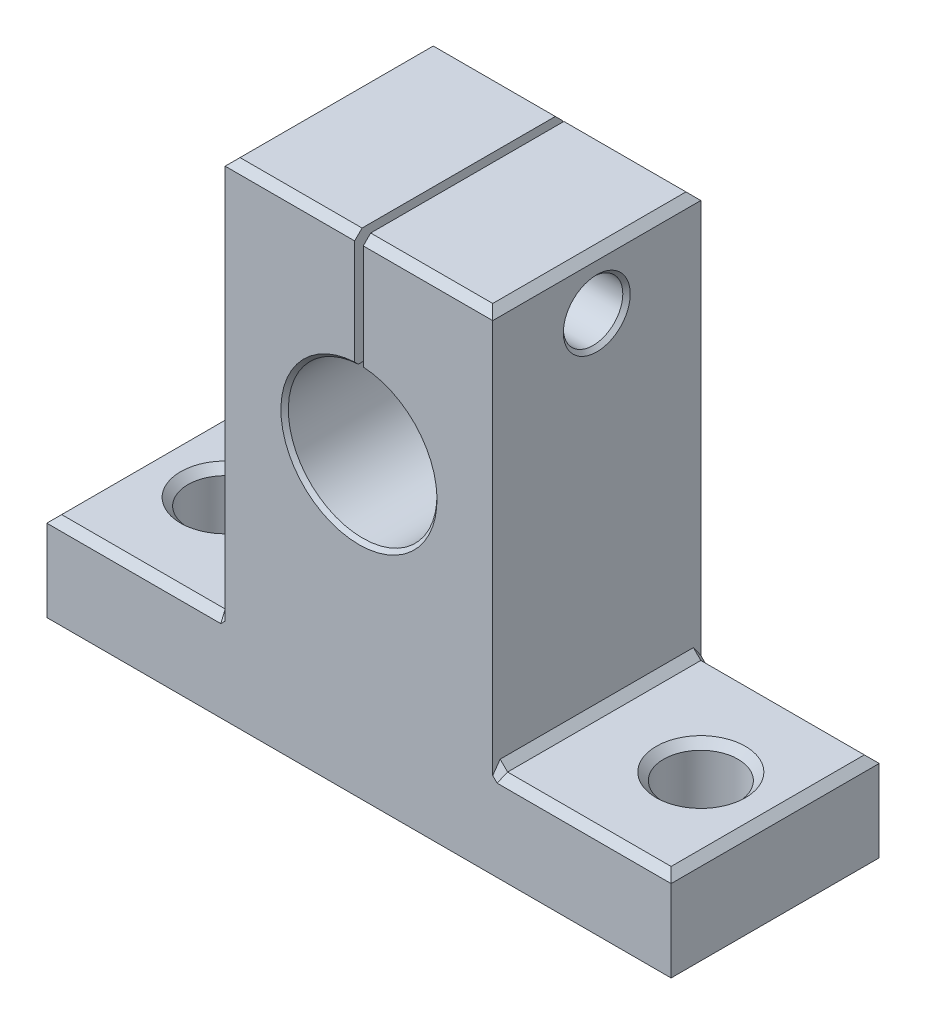
from build123d import *

# Parameters (mm, degrees)
BOSS_EXTRUDE1_DEPTH = 14
CHAMFER1_SIZE       = 0.5
CHAMFER2_SIZE       = 0.5
CHAMFER3_SIZE       = 0.5
CHAMFER4_SIZE       = 0.5
CHAMFER5_SIZE       = 0.5
CHAMFER6_SIZE       = 0.5
SKETCH2_R           = 5
CUT_EXTRUDE2_DEPTH  = 14
CUT_EXTRUDE3_DEPTH  = 14
SKETCH4_R           = 2
CUT_EXTRUDE4_DEPTH  = 25
SKETCH5_R           = 2.5
CUT_EXTRUDE5_DEPTH  = 25
CHAMFER7_SIZE       = 0.5
CHAMFER8_SIZE       = 0.5
CHAMFER9_SIZE       = 0.5
CHAMFER10_SIZE      = 0.5
CHAMFER11_SIZE      = 0.5
CHAMFER12_SIZE      = 0.5
CHAMFER13_SIZE      = 0.5
CHAMFER14_SIZE      = 0.5
CHAMFER15_SIZE      = 0.5
CHAMFER16_SIZE      = 0.25
CHAMFER17_SIZE      = 0.25
CHAMFER18_SIZE      = 0.25


with BuildPart() as part:
    # Sketch1 → Boss-Extrude1 (new body)
    with BuildSketch(Plane.XY):
        Polygon((-0.421052632, -3.746003341), (-0.421052632, 23.053996659), (17.578947368, 23.053996659), (17.578947368, -3.746003341), (29.578947368, -3.746003341), (29.578947368, -9.746003341), (-12.421052632, -9.746003341), (-12.421052632, -3.746003341), align=None)
    extrude(amount=BOSS_EXTRUDE1_DEPTH)

    # Chamfer1
    chamfer1_edges = [part.edges().sort_by_distance(p)[0] for p in [
        (17.578947368, -3.746003341, 7),
    ]]
    chamfer(chamfer1_edges, length=CHAMFER1_SIZE)

    # Chamfer2
    chamfer2_edges = [part.edges().sort_by_distance(p)[0] for p in [
        (-0.421052632, -3.746003341, 7),
    ]]
    chamfer(chamfer2_edges, length=CHAMFER2_SIZE)

    # Chamfer3
    chamfer3_edges = [part.edges().sort_by_distance(p)[0] for p in [
        (-12.421052632, -3.746003341, 7),
    ]]
    chamfer(chamfer3_edges, length=CHAMFER3_SIZE)

    # Chamfer4
    chamfer4_edges = [part.edges().sort_by_distance(p)[0] for p in [
        (29.578947368, -3.746003341, 7),
    ]]
    chamfer(chamfer4_edges, length=CHAMFER4_SIZE)

    # Chamfer5
    chamfer5_edges = [part.edges().sort_by_distance(p)[0] for p in [
        (17.578947368, 23.053996659, 7),
    ]]
    chamfer(chamfer5_edges, length=CHAMFER5_SIZE)

    # Chamfer6
    chamfer6_edges = [part.edges().sort_by_distance(p)[0] for p in [
        (-0.421052632, 23.053996659, 7),
    ]]
    chamfer(chamfer6_edges, length=CHAMFER6_SIZE)

    # Sketch2 → Cut-Extrude2 (cut)
    with BuildSketch(Plane.XY.offset(14)):
        with Locations((8.578947368, 10.253996659)):
            Circle(SKETCH2_R)
    extrude(amount=-CUT_EXTRUDE2_DEPTH, mode=Mode.SUBTRACT)

    # Sketch3 → Cut-Extrude3 (cut)
    with BuildSketch(Plane.XY.offset(14)):
        Polygon((8.288550375, 23.332002233), (8.288550375, 14.543053955), (8.869344362, 14.973079178), (8.869344362, 23.332002233), align=None)
    extrude(amount=-CUT_EXTRUDE3_DEPTH, mode=Mode.SUBTRACT)

    # Sketch4 → Cut-Extrude4 (cut)
    with BuildSketch(Plane(origin=(17.578947368, 0, 0), x_dir=(0, 0, -1), z_dir=(1, 0, 0))):
        with Locations((-7, 19.481136132)):
            Circle(SKETCH4_R)
    extrude(amount=-CUT_EXTRUDE4_DEPTH, mode=Mode.SUBTRACT)

    # Sketch5 → Cut-Extrude5 (cut)
    with BuildSketch(Plane.XZ.offset(9.746003341)):
        with Locations((-7.421052632, 7)):
            Circle(SKETCH5_R)
        with Locations((24.578947368, 7)):
            Circle(SKETCH5_R)
    extrude(amount=-CUT_EXTRUDE5_DEPTH, mode=Mode.SUBTRACT)

    # Chamfer7
    chamfer7_edges = [part.edges().sort_by_distance(p)[0] for p in [
        (-9.921052632, -3.746003341, 7),
    ]]
    chamfer(chamfer7_edges, length=CHAMFER7_SIZE)

    # Chamfer8
    chamfer8_edges = [part.edges().sort_by_distance(p)[0] for p in [
        (22.078947368, -3.746003341, 7),
    ]]
    chamfer(chamfer8_edges, length=CHAMFER8_SIZE)

    # Chamfer9
    chamfer9_edges = [part.edges().sort_by_distance(p)[0] for p in [
        (23.578947368, -3.746003341, 14),
    ]]
    chamfer(chamfer9_edges, length=CHAMFER9_SIZE)

    # Chamfer10
    chamfer10_edges = [part.edges().sort_by_distance(p)[0] for p in [
        (18.328947368, -3.996003341, 14),
    ]]
    chamfer(chamfer10_edges, length=CHAMFER10_SIZE)

    # Chamfer11
    chamfer11_edges = [part.edges().sort_by_distance(p)[0] for p in [
        (23.578947368, -3.746003341, 0),
    ]]
    chamfer(chamfer11_edges, length=CHAMFER11_SIZE)

    # Chamfer12
    chamfer12_edges = [part.edges().sort_by_distance(p)[0] for p in [
        (18.328947368, -3.996003341, 0),
    ]]
    chamfer(chamfer12_edges, length=CHAMFER12_SIZE)

    # Chamfer13
    chamfer13_edges = [part.edges().sort_by_distance(p)[0] for p in [
        (4.183748872, 23.053996659, 0),
        (12.974145865, 23.053996659, 0),
    ]]
    chamfer(chamfer13_edges, length=CHAMFER13_SIZE)

    # Chamfer14
    chamfer14_edges = [part.edges().sort_by_distance(p)[0] for p in [
        (12.974145865, 23.053996659, 14),
        (4.183748872, 23.053996659, 14),
    ]]
    chamfer(chamfer14_edges, length=CHAMFER14_SIZE)

    # Chamfer15
    chamfer15_edges = [part.edges().sort_by_distance(p)[0] for p in [
        (-0.671052632, -3.496003341, 0),
        (-6.421052632, -3.746003341, 0),
        (-0.671052632, -3.496003341, 14),
        (-6.421052632, -3.746003341, 14),
    ]]
    chamfer(chamfer15_edges, length=CHAMFER15_SIZE)

    # Chamfer16
    chamfer16_edges = [part.edges().sort_by_distance(p)[0] for p in [
        (5.147619999, 6.617240896, 0),
        (5.147619999, 6.617240896, 14),
    ]]
    chamfer(chamfer16_edges, length=CHAMFER16_SIZE)

    # Chamfer17
    chamfer17_edges = [part.edges().sort_by_distance(p)[0] for p in [
        (-0.421052632, 19.481136132, 9),
    ]]
    chamfer(chamfer17_edges, length=CHAMFER17_SIZE)

    # Chamfer18
    chamfer18_edges = [part.edges().sort_by_distance(p)[0] for p in [
        (17.578947368, 19.481136132, 9),
    ]]
    chamfer(chamfer18_edges, length=CHAMFER18_SIZE)


solid = part.part
